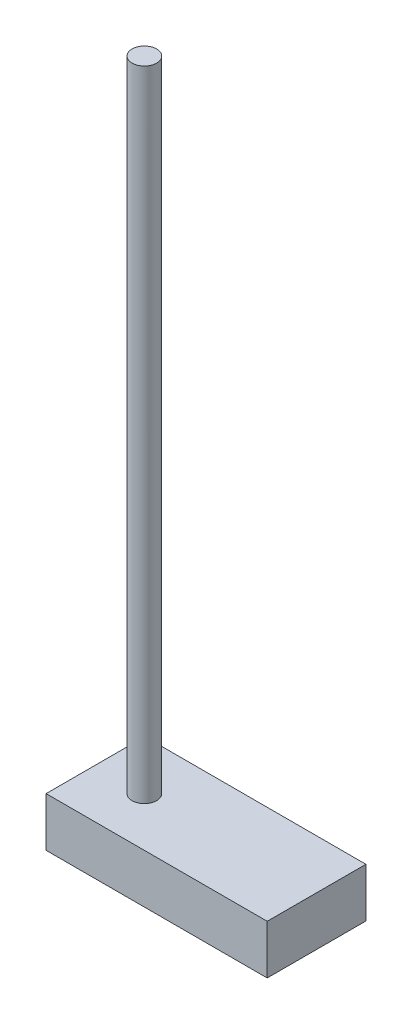
from build123d import *

# Parameters (mm, degrees)
CROQUIS1_R              = 2.5
SALIENTE_EXTRUIR1_DEPTH = 20
CROQUIS2_W              = 45
CROQUIS2_H              = 20.08756727
SALIENTE_EXTRUIR2_DEPTH = 10
CROQUIS3_R              = 2.5
SALIENTE_EXTRUIR3_DEPTH = 110


with BuildPart() as part:
    # Croquis1 → Saliente-Extruir1 (new body)
    with BuildSketch(Plane(origin=(0, 0, 0), x_dir=(1, 0, 0), z_dir=(0, 1, 0))):
        Circle(CROQUIS1_R)
    extrude(amount=SALIENTE_EXTRUIR1_DEPTH)

    # Croquis2 → Saliente-Extruir2 (add)
    with BuildSketch(Plane.XZ):
        with Locations((12.5, -0.043783635)):
            Rectangle(CROQUIS2_W, CROQUIS2_H)
    extrude(amount=SALIENTE_EXTRUIR2_DEPTH)

    # Croquis3 → Saliente-Extruir3 (add)
    with BuildSketch(Plane(origin=(0, 20, 0), x_dir=(1, 0, 0), z_dir=(0, 1, 0))):
        Circle(CROQUIS3_R)
    extrude(amount=SALIENTE_EXTRUIR3_DEPTH)


solid = part.part
